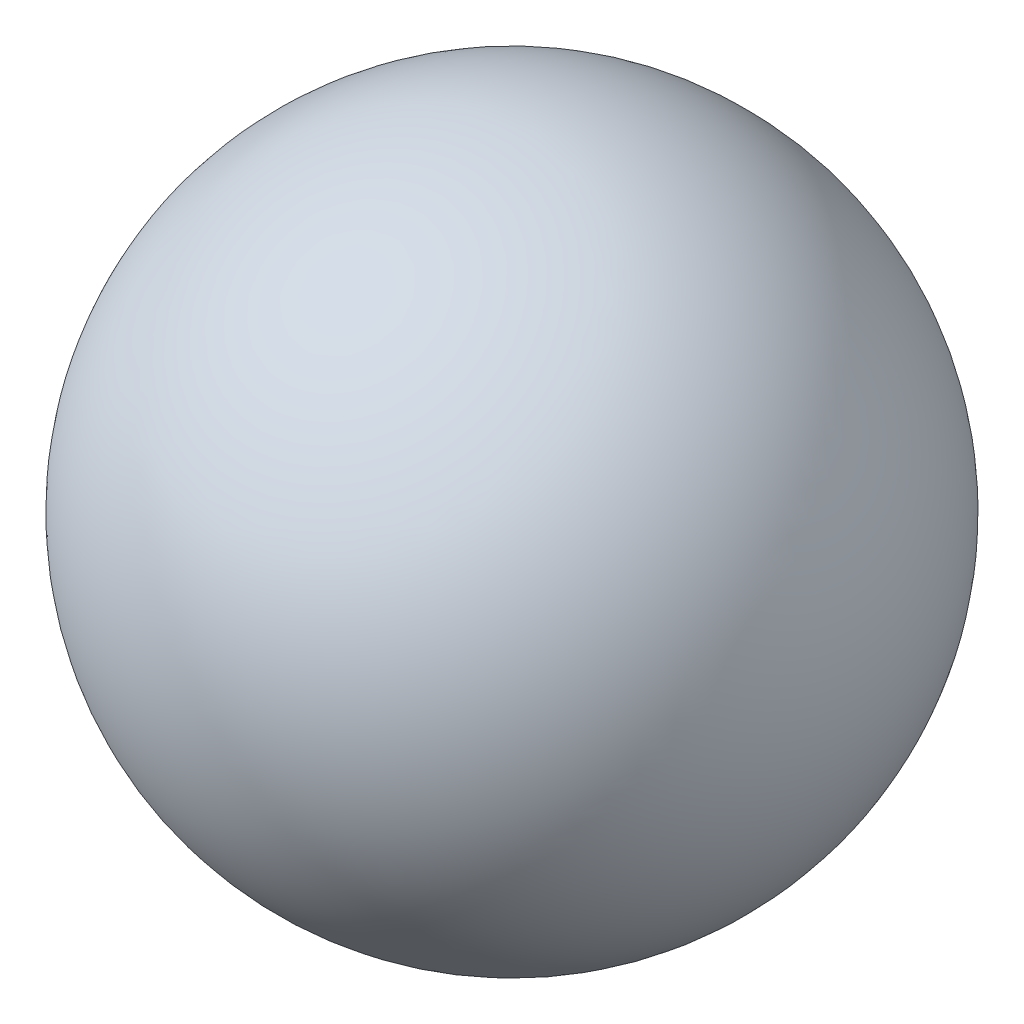
from build123d import *


with BuildPart() as part:
    # Esquisse1 → Révolution1 (revolve)
    with BuildSketch(Plane.XY):
        with BuildLine():
            Line((-40, 0), (40, 0))
            ThreePointArc((40, 0), (0, -40), (-40, 0))
        make_face()
    revolve(axis=Axis((-40, 0, 0), (1, 0, 0)))


solid = part.part
